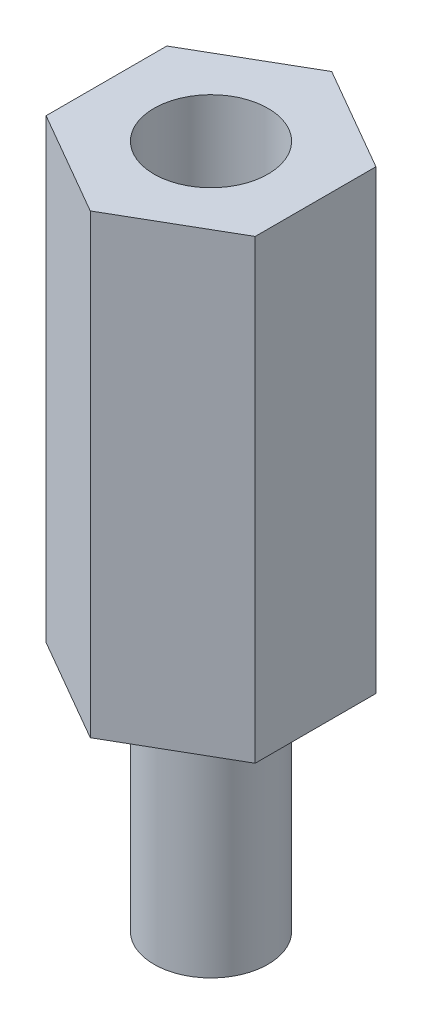
from build123d import *

# Parameters (mm, degrees)
SALIENTE_EXTRUIR1_DEPTH = 12
CROQUIS2_R              = 1.5
SALIENTE_EXTRUIR2_DEPTH = 6
CROQUIS3_R              = 1.5
CORTAR_EXTRUIR1_DEPTH   = 6


with BuildPart() as part:
    # Croquis1 → Saliente-Extruir1 (new body)
    with BuildSketch(Plane(origin=(0, 0, 0), x_dir=(1, 0, 0), z_dir=(0, 1, 0))):
        Polygon((0, 3.175426481), (-2.75, 1.58771324), (-2.75, -1.58771324), (0, -3.175426481), (2.75, -1.58771324), (2.75, 1.58771324), align=None)
    extrude(amount=SALIENTE_EXTRUIR1_DEPTH)

    # Croquis2 → Saliente-Extruir2 (add)
    with BuildSketch(Plane.XZ):
        Circle(CROQUIS2_R)
    extrude(amount=SALIENTE_EXTRUIR2_DEPTH)

    # Croquis3 → Cortar-Extruir1 (cut)
    with BuildSketch(Plane(origin=(0, 12, 0), x_dir=(1, 0, 0), z_dir=(0, 1, 0))):
        Circle(CROQUIS3_R)
    extrude(amount=-CORTAR_EXTRUIR1_DEPTH, mode=Mode.SUBTRACT)


solid = part.part
